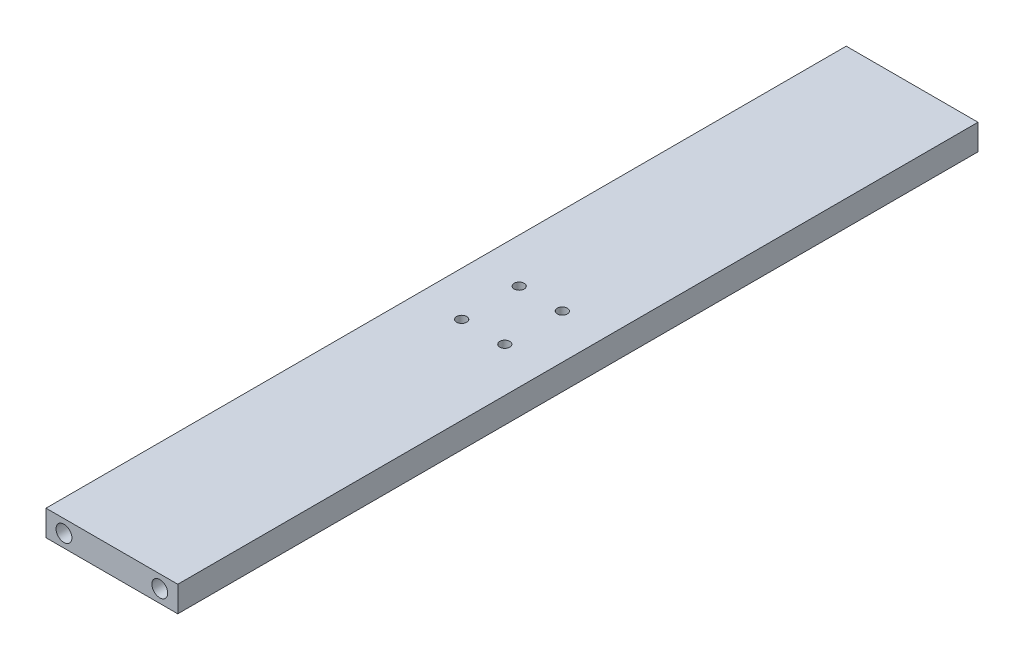
from build123d import *

# Parameters (mm, degrees)
ESBO_O1_W                                   = 55
ESBO_O1_H                                   = 10.7
RESSALTO_EXTRUS_O1_DEPTH                    = 334
FURO_ROSCADO_PARA_CONDU_TE_DE_M4X0_71_D     = 4.2
FURO_ROSCADO_PARA_CONDU_TE_DE_1_4_281_D     = 6.6294
FURO_ROSCADO_PARA_CONDU_TE_DE_1_4_281_DEPTH = 15
FURO_ROSCADO_PARA_CONDU_TE_DE_1_4_281_TIP   = 1.991672694
FURO_ROSCADO_PARA_CONDU_TE_DE_1_4_282_D     = 6.6294
FURO_ROSCADO_PARA_CONDU_TE_DE_1_4_282_DEPTH = 15
FURO_ROSCADO_PARA_CONDU_TE_DE_1_4_282_TIP   = 1.991672694


with BuildPart() as part:
    # Esboço1 → Ressalto-extrusão1 (new body)
    with BuildSketch(Plane.XY):
        Rectangle(ESBO_O1_W, ESBO_O1_H)
    extrude(amount=RESSALTO_EXTRUS_O1_DEPTH)

    # Furo roscado para conduíte de M4x0.71 (through all)
    with Locations(Plane(origin=(0, -5.35, 0), x_dir=(-1, 0, 0), z_dir=(0, -1, 0))):
        with Locations((9, -155), (-9, -155), (-9, -179), (9, -179)):
            Hole(FURO_ROSCADO_PARA_CONDU_TE_DE_M4X0_71_D / 2)

    # Furo roscado para conduíte de 1/4-281
    with Locations(Plane.XY.offset(334)):
        with Locations((-20, 0), (20, 0)):
            Hole(FURO_ROSCADO_PARA_CONDU_TE_DE_1_4_281_D / 2, depth=FURO_ROSCADO_PARA_CONDU_TE_DE_1_4_281_DEPTH)
            with Locations((0, 0, -(FURO_ROSCADO_PARA_CONDU_TE_DE_1_4_281_DEPTH + FURO_ROSCADO_PARA_CONDU_TE_DE_1_4_281_TIP / 2))):  # 118° drill point
                Cone(0, FURO_ROSCADO_PARA_CONDU_TE_DE_1_4_281_D / 2, FURO_ROSCADO_PARA_CONDU_TE_DE_1_4_281_TIP, mode=Mode.SUBTRACT)

    # Furo roscado para conduíte de 1/4-282
    with Locations(Plane(origin=(0, 0, 0), x_dir=(-1, 0, 0), z_dir=(0, 0, -1))):
        with Locations((-20, 0), (20, 0)):
            Hole(FURO_ROSCADO_PARA_CONDU_TE_DE_1_4_282_D / 2, depth=FURO_ROSCADO_PARA_CONDU_TE_DE_1_4_282_DEPTH)
            with Locations((0, 0, -(FURO_ROSCADO_PARA_CONDU_TE_DE_1_4_282_DEPTH + FURO_ROSCADO_PARA_CONDU_TE_DE_1_4_282_TIP / 2))):  # 118° drill point
                Cone(0, FURO_ROSCADO_PARA_CONDU_TE_DE_1_4_282_D / 2, FURO_ROSCADO_PARA_CONDU_TE_DE_1_4_282_TIP, mode=Mode.SUBTRACT)


solid = part.part
